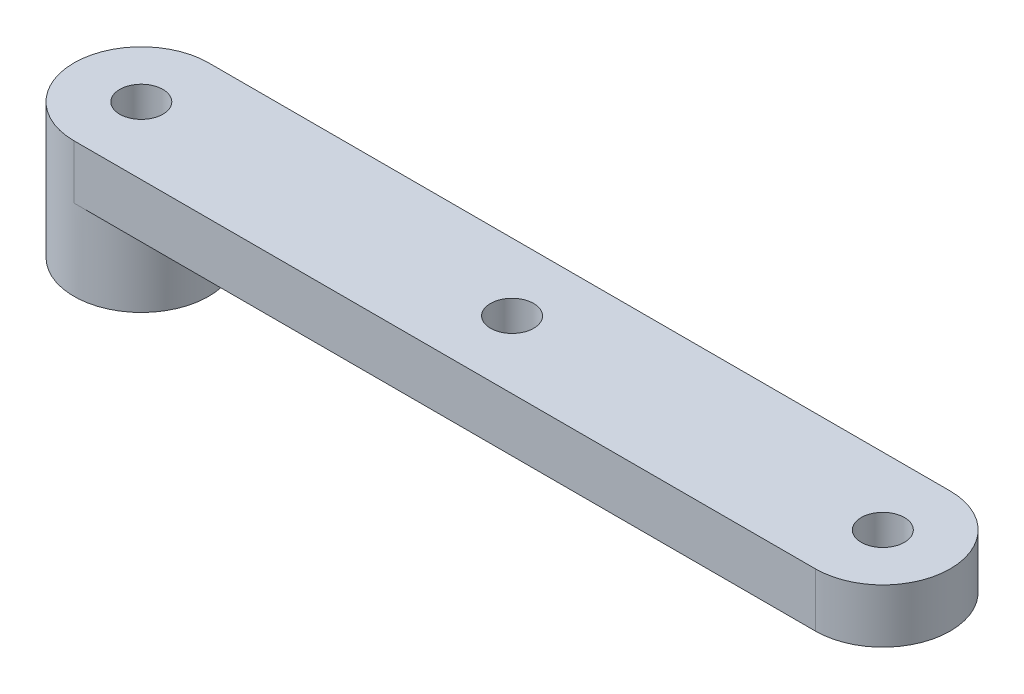
from build123d import *

# Parameters (mm, degrees)
BOSS_EXTRUDE1_DEPTH = 4
SKETCH2_R           = 1.6
CUT_EXTRUDE1_DEPTH  = 5
SKETCH3_R           = 5
BOSS_EXTRUDE2_DEPTH = 6
SKETCH5_R           = 1.6
CUT_EXTRUDE2_DEPTH  = 6


with BuildPart() as part:
    # Sketch1 → Boss-Extrude1 (new body)
    with BuildSketch(Plane(origin=(0, 0, 0), x_dir=(1, 0, 0), z_dir=(0, 1, 0))):
        with BuildLine():
            Line((0, 5), (55, 5))
            ThreePointArc((55, 5), (60, 0), (55, -5))
            Line((55, -5), (0, -5))
            ThreePointArc((0, -5), (-5, 0), (0, 5))
        make_face()
    extrude(amount=BOSS_EXTRUDE1_DEPTH)

    # Sketch2 → Cut-Extrude1 (cut, through all)
    with BuildSketch(Plane(origin=(0, 4, 0), x_dir=(1, 0, 0), z_dir=(0, 1, 0))):
        Circle(SKETCH2_R)
        with Locations((27.5, 0)):
            Circle(SKETCH2_R)
        with Locations((55, 0)):
            Circle(SKETCH2_R)
    extrude(amount=-CUT_EXTRUDE1_DEPTH, mode=Mode.SUBTRACT)

    # Sketch3 → Boss-Extrude2 (add)
    with BuildSketch(Plane.XZ):
        Circle(SKETCH3_R)
    extrude(amount=BOSS_EXTRUDE2_DEPTH)

    # Sketch5 → Cut-Extrude2 (cut)
    with BuildSketch(Plane.XZ.offset(6)):
        Circle(SKETCH5_R)
    extrude(amount=-CUT_EXTRUDE2_DEPTH, mode=Mode.SUBTRACT)


solid = part.part
